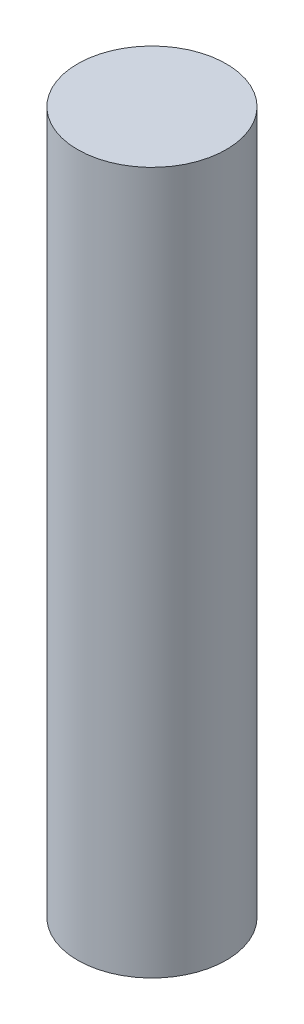
from build123d import *

# Parameters (mm, degrees)
SKETCH1_R           = 914.4
BOSS_EXTRUDE1_DEPTH = 8636


with BuildPart() as part:
    # Sketch1 → Boss-Extrude1 (new body)
    with BuildSketch(Plane(origin=(0, 0, 0), x_dir=(1, 0, 0), z_dir=(0, 1, 0))):
        Circle(SKETCH1_R)
    extrude(amount=BOSS_EXTRUDE1_DEPTH)


solid = part.part
